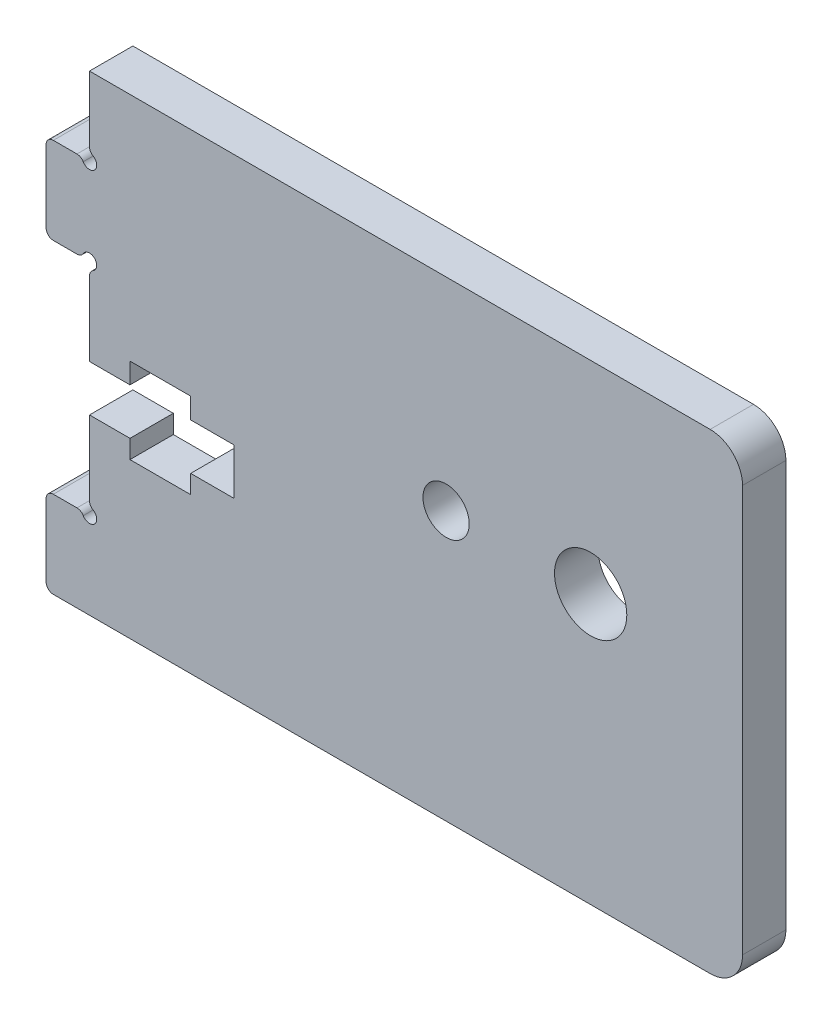
from build123d import *

# Parameters (mm, degrees)
MODEL_R             = 1.6
MODEL_R_2           = 2.5
BOSS_EXTRUDE1_DEPTH = 3


with BuildPart() as part:
    # Model → Boss-Extrude1 (new body)
    with BuildSketch(Plane.XY):
        with BuildLine():
            Line((146.020094854, 163.929669503), (146.020094854, 158.929672503))
            ThreePointArc((146.020094854, 158.929672503), (146.166539616, 158.576119306), (146.520091281, 158.429670848))
            Line((146.520091281, 158.429670848), (191.949370202, 158.429670848))
            ThreePointArc((191.949370202, 158.429670848), (193.533289392, 159.085751658), (194.189370202, 160.669670848))
            Line((194.189370202, 160.669670848), (194.189370202, 188.789666848))
            ThreePointArc((194.189370202, 188.789666848), (193.533289392, 190.373586038), (191.949370202, 191.029666848))
            Line((191.949370202, 191.029666848), (149.020161786, 191.029666848))
            Line((149.020161786, 191.029666848), (149.020161786, 186.495697517))
            ThreePointArc((149.020161786, 186.495697517), (149.087148935, 186.245697179), (149.270161786, 186.062684219))
            ThreePointArc((149.270161786, 186.062684219), (149.373716972, 185.276118333), (148.587150624, 185.379670014))
            ThreePointArc((148.587150624, 185.379670014), (148.404138038, 185.562681651), (148.154138786, 185.629668517))
            Line((148.154138786, 185.629668517), (146.520109786, 185.629668517))
            ThreePointArc((146.520109786, 185.629668517), (146.166556395, 185.483221908), (146.020109786, 185.129668517))
            Line((146.020109786, 185.129668517), (146.020109786, 180.129671517))
            ThreePointArc((146.020109786, 180.129671517), (146.166554627, 179.776114895), (146.520109786, 179.629666517))
            Line((146.520109786, 179.629666517), (148.154138786, 179.629666517))
            ThreePointArc((148.154138786, 179.629666517), (148.404140189, 179.696653822), (148.587154607, 179.879666726))
            ThreePointArc((148.587154607, 179.879666726), (149.373734927, 179.983242082), (149.270155207, 179.196662336))
            ThreePointArc((149.270155207, 179.196662336), (149.087143628, 179.013649891), (149.02015667, 178.76365081))
            Line((149.02015667, 178.76365081), (149.02015667, 173.629671744))
            Line((149.02015667, 173.629671744), (151.82015667, 173.629671744))
            Line((151.82015667, 173.629671744), (151.82015667, 175.054680432))
            Line((151.82015667, 175.054680432), (156.020152766, 175.054680432))
            Line((156.020152766, 175.054680432), (156.020152766, 173.629670513))
            Line((156.020152766, 173.629670513), (159.020147427, 173.629670513))
            Line((159.020147427, 173.629670513), (159.020147427, 170.429672075))
            Line((159.020147427, 170.429672075), (156.020147427, 170.429672075))
            Line((156.020147427, 170.429672075), (156.020147427, 169.154680763))
            Line((156.020147427, 169.154680763), (151.820147427, 169.154680763))
            Line((151.820147427, 169.154680763), (151.820147427, 170.429672075))
            Line((151.820147427, 170.429672075), (149.020147427, 170.429672075))
            Line((149.020147427, 170.429672075), (149.020147427, 165.295696252))
            ThreePointArc((149.020147427, 165.295696252), (149.08713456, 165.045696208), (149.270147141, 164.862683385))
            ThreePointArc((149.270147141, 164.862683385), (149.373701806, 164.07611743), (148.587135527, 164.179669631))
            ThreePointArc((148.587135527, 164.179669631), (148.404130845, 164.362680921), (148.154138455, 164.429670848))
            Line((148.154138455, 164.429670848), (146.520087311, 164.429670848))
            ThreePointArc((146.520087311, 164.429670848), (146.166538715, 164.283220702), (146.020094854, 163.929669503))
        make_face()
        with Locations((173.68542699, 177.029665772)):
            Circle(MODEL_R, mode=Mode.SUBTRACT)
        with Locations((183.68542699, 177.029665772)):
            Circle(MODEL_R_2, mode=Mode.SUBTRACT)
    extrude(amount=BOSS_EXTRUDE1_DEPTH)


solid = part.part
